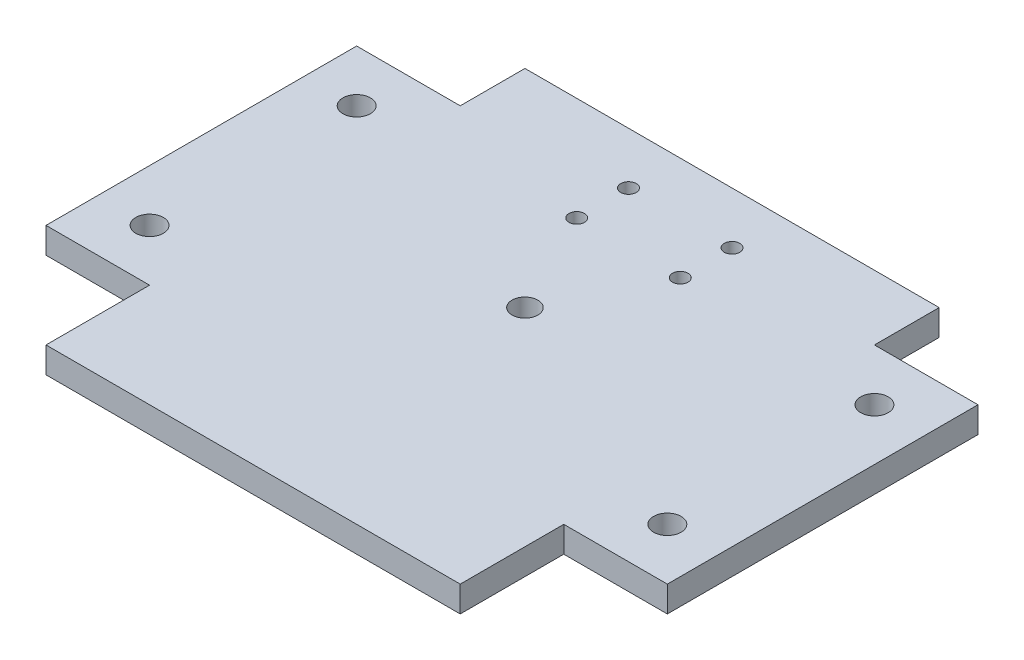
from build123d import *

# Parameters (mm, degrees)
SKETCH1_R           = 3.3782
SKETCH1_R_2         = 1.905
SKETCH1_R_3         = 3.175
BOSS_EXTRUDE1_DEPTH = 6.35


with BuildPart() as part:
    # Sketch1 → Boss-Extrude1 (new body)
    with BuildSketch(Plane(origin=(0, 0, 0), x_dir=(1, 0, 0), z_dir=(0, 1, 0))):
        Polygon((25.4, 25.4), (25.4, 0), (127, 0), (127, 25.4), (152.4, 25.4), (152.4, 101.6), (127, 101.6), (127, 117.475), (25.4, 117.475), (25.4, 101.6), (0, 101.6), (0, 25.4), align=None)
        with Locations((12.7, 38.1)):
            Circle(SKETCH1_R, mode=Mode.SUBTRACT)
        with Locations((139.7, 38.1)):
            Circle(SKETCH1_R, mode=Mode.SUBTRACT)
        with Locations((12.7, 88.9)):
            Circle(SKETCH1_R, mode=Mode.SUBTRACT)
        with Locations((63.5, 92.075)):
            Circle(SKETCH1_R_2, mode=Mode.SUBTRACT)
        with Locations((63.5, 104.775)):
            Circle(SKETCH1_R_2, mode=Mode.SUBTRACT)
        with Locations((76.2, 66.675)):
            Circle(SKETCH1_R_3, mode=Mode.SUBTRACT)
        with Locations((88.9, 92.075)):
            Circle(SKETCH1_R_2, mode=Mode.SUBTRACT)
        with Locations((88.9, 104.775)):
            Circle(SKETCH1_R_2, mode=Mode.SUBTRACT)
        with Locations((139.7, 88.9)):
            Circle(SKETCH1_R, mode=Mode.SUBTRACT)
    extrude(amount=BOSS_EXTRUDE1_DEPTH)


solid = part.part
